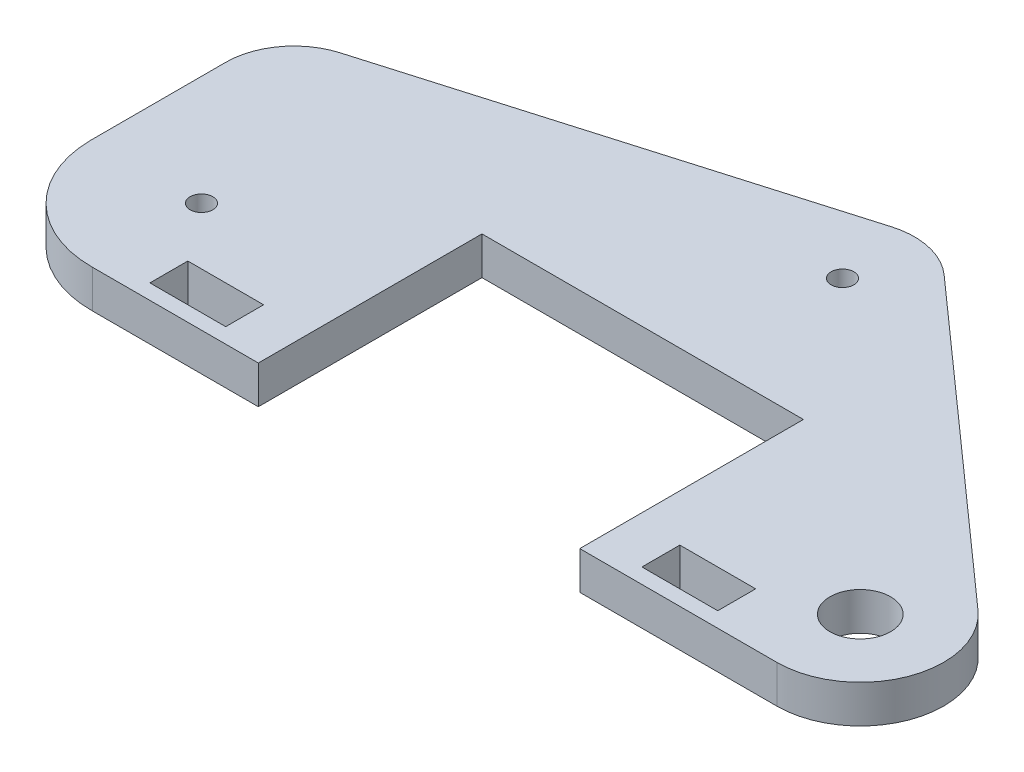
from build123d import *

# Parameters (mm, degrees)
SKETCH1_R           = 1.5
SKETCH1_R_2         = 4
SKETCH1_W           = 10
SKETCH1_H           = 5
BOSS_EXTRUDE1_DEPTH = 5


with BuildPart() as part:
    # Sketch1 → Boss-Extrude1 (new body)
    with BuildSketch(Plane(origin=(0, 0, 0), x_dir=(1, 0, 0), z_dir=(0, 1, 0))):
        with BuildLine():
            Line((0.102834293, -14.499635344), (22.002834293, -14.499635344))
            Line((22.002834293, -14.499635344), (22.002834293, 15.000364656))
            Line((22.002834293, 15.000364656), (64.402834293, 15.000364656))
            Line((64.402834293, 15.000364656), (64.402834293, -14.499635344))
            Line((64.402834293, -14.499635344), (90.402834293, -14.499635344))
            ThreePointArc((90.402834293, -14.499635344), (100.683758076, -7.411489913), (97.715103143, 4.718072625))
            Line((97.715103143, 4.718072625), (57.168590047, 40.797111428))
            ThreePointArc((57.168590047, 40.797111428), (52.935602616, 42.969014799), (48.180396076, 42.816182826))
            Line((48.180396076, 42.816182826), (-8.032001051, 26.333549436))
            ThreePointArc((-8.032001051, 26.333549436), (-12.703498591, 23.092010868), (-14.499635344, 17.697165707))
            Line((-14.499635344, 17.697165707), (-14.499635344, -0.102834293))
            ThreePointArc((-14.499635344, -0.102834293), (-10.18007565, -10.325505303), (0.102834293, -14.499635344))
        make_face()
        Circle(SKETCH1_R, mode=Mode.SUBTRACT)
        with Locations((90.402834293, -3.499635344)):
            Circle(SKETCH1_R_2, mode=Mode.SUBTRACT)
        with Locations((50.853448768, 33.7)):
            Circle(SKETCH1_R, mode=Mode.SUBTRACT)
        with Locations((10.7, -9.999635344)):
            Rectangle(SKETCH1_W, SKETCH1_H, mode=Mode.SUBTRACT)
        with Locations((75.602834293, -9.999635344)):
            Rectangle(SKETCH1_W, SKETCH1_H, mode=Mode.SUBTRACT)
    extrude(amount=BOSS_EXTRUDE1_DEPTH)


solid = part.part
